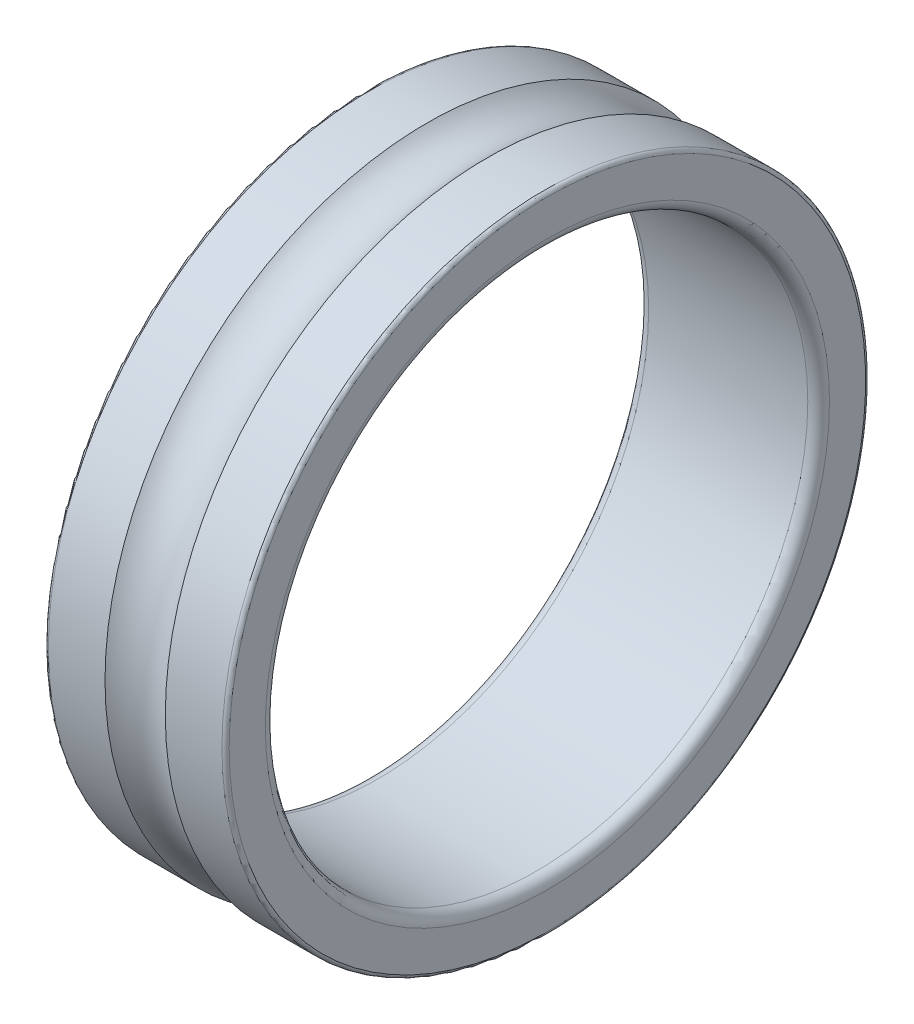
from build123d import *


with BuildPart() as part:
    # 草图1 → 旋转1 (revolve)
    with BuildSketch(Plane.XY):
        with BuildLine():
            Line((0, 8.8), (0, 7.8))
            ThreePointArc((0, 7.8), (0.087867966, 7.587867966), (0.3, 7.5))
            Line((0.3, 7.5), (4.7, 7.5))
            ThreePointArc((4.7, 7.5), (4.912132034, 7.587867966), (5, 7.8))
            Line((5, 7.8), (5, 8.8))
            ThreePointArc((5, 8.8), (4.970710678, 8.870710678), (4.9, 8.9))
            Line((4.9, 8.9), (3.333540791, 8.9))
            ThreePointArc((3.333540791, 8.9), (2.5, 8.5595), (1.666459209, 8.9))
            Line((1.666459209, 8.9), (0.1, 8.9))
            ThreePointArc((0.1, 8.9), (0.029289322, 8.870710678), (0, 8.8))
        make_face()
    revolve(axis=Axis((50, 0, 0), (-1, 0, 0)))


solid = part.part
